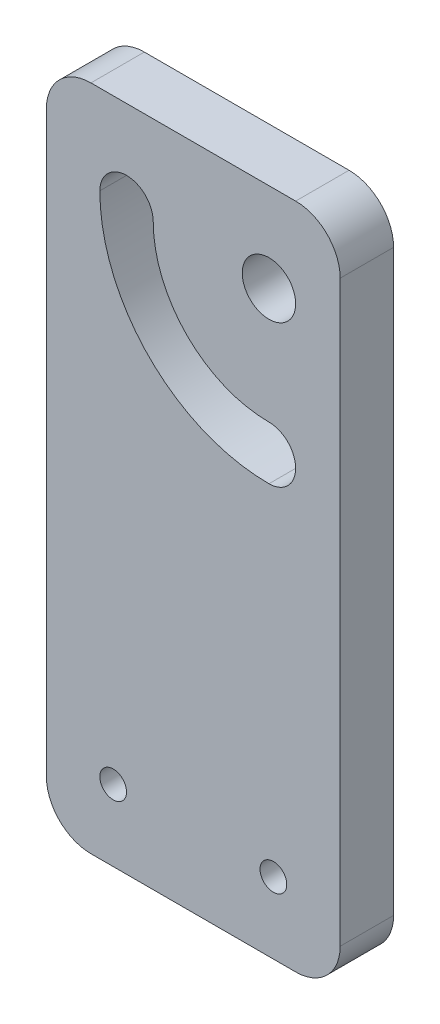
from build123d import *

# Parameters (mm, degrees)
ESBO_O1_R                = 3
ESBO_O1_R_2              = 1.5
RESSALTO_EXTRUS_O2_DEPTH = 6


with BuildPart() as part:
    # Esboço1 → Ressalto-extrusão2 (new body)
    with BuildSketch(Plane.XY):
        with BuildLine():
            Line((5, 50), (28, 50))
            ThreePointArc((28, 50), (31.535533906, 48.535533906), (33, 45))
            Line((33, 45), (33, -20))
            ThreePointArc((33, -20), (31.535533906, -23.535533906), (28, -25))
            Line((28, -25), (5, -25))
            ThreePointArc((5, -25), (1.464466094, -23.535533906), (0, -20))
            Line((0, -20), (0, 45))
            ThreePointArc((0, 45), (1.464466094, 48.535533906), (5, 50))
        make_face()
        with Locations((25, 40)):
            Circle(ESBO_O1_R, mode=Mode.SUBTRACT)
        with Locations((25.5, -17)):
            Circle(ESBO_O1_R_2, mode=Mode.SUBTRACT)
        with Locations((7.5, -17)):
            Circle(ESBO_O1_R_2, mode=Mode.SUBTRACT)
        with BuildLine():
            ThreePointArc((6, 40), (11.564971157, 26.564971157), (25, 21))
            ThreePointArc((25, 21), (28, 24), (25, 27))
            ThreePointArc((25, 27), (15.807611845, 30.807611845), (12, 40))
            ThreePointArc((12, 40), (9, 43), (6, 40))
        make_face(mode=Mode.SUBTRACT)
    extrude(amount=RESSALTO_EXTRUS_O2_DEPTH)


solid = part.part
